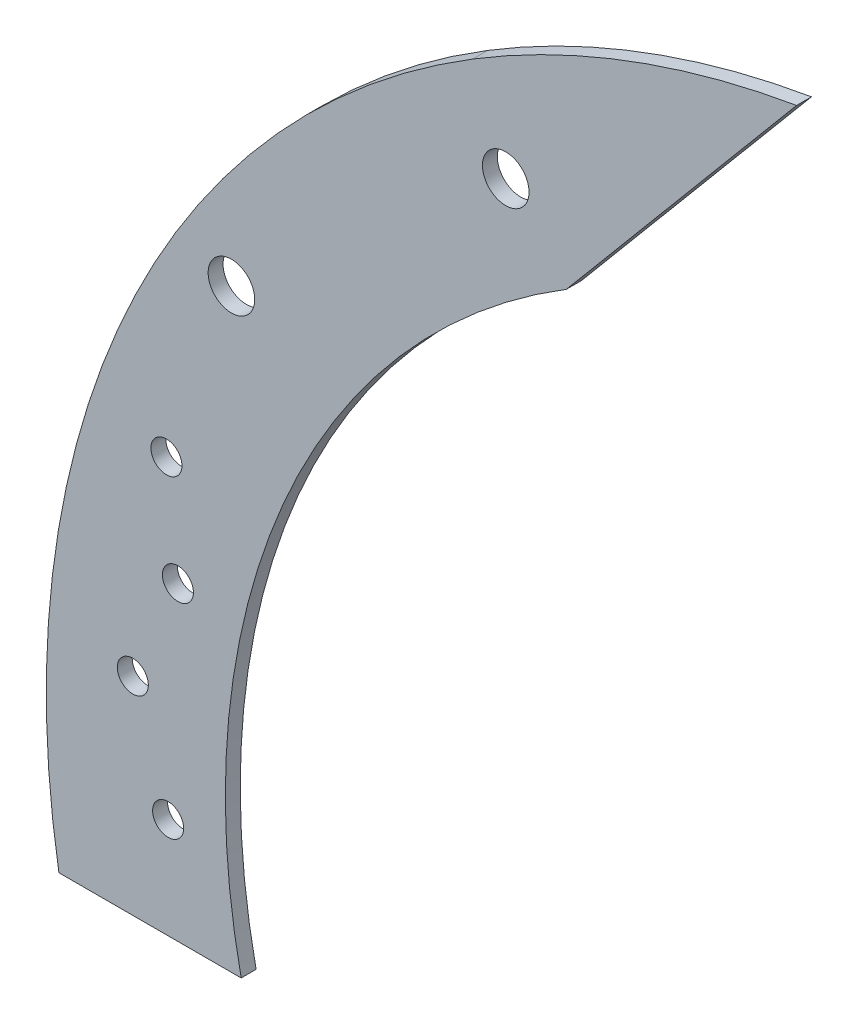
from build123d import *

# Parameters (mm, degrees)
BOSS_EXTRUDE1_DEPTH              = 3.175
SKETCH2_R                        = 3.302
CUT_EXTRUDE1_DEPTH               = 3.175
SKETCH3_R                        = 3.302
CUT_EXTRUDE2_DEPTH               = 3.175
F_25_64_0_39063_DIAMETER_HOLE1_D = 9.922002


with BuildPart() as part:
    # Sketch1 → Boss-Extrude1 (new body)
    with BuildSketch(Plane.XY):
        with BuildLine():
            Line((-150.65739054, -36.5125), (-189.445196846, -36.5125))
            ThreePointArc((-189.445196846, -36.5125), (-175.12424315, 73.983329), (-101.363819659, 157.492716901))
            ThreePointArc((-101.363819659, 157.492716901), (-68.153294369, 173.730017516), (-32.46878203, 183.38426531))
            Line((-32.46878203, 183.38426531), (-81.449197888, 125.011678745))
            ThreePointArc((-81.449197888, 125.011678745), (-141.744884659, 55.257653644), (-150.65739054, -36.5125))
        make_face()
    extrude(amount=BOSS_EXTRUDE1_DEPTH)

    # Sketch2 → Cut-Extrude1 (cut)
    with BuildSketch(Plane.XY.offset(3.175)):
        with Locations((-166.205357894, -15.073647178)):
            Circle(SKETCH2_R)
        with Locations((-164.125827505, 29.433503815)):
            Circle(SKETCH2_R)
    extrude(amount=-CUT_EXTRUDE1_DEPTH, mode=Mode.SUBTRACT)

    # Sketch3 → Cut-Extrude2 (cut)
    with BuildSketch(Plane.XY.offset(3.175)):
        with Locations((-173.718655592, 7.579557452)):
            Circle(SKETCH3_R)
        with Locations((-166.564839951, 51.569288407)):
            Circle(SKETCH3_R)
    extrude(amount=-CUT_EXTRUDE2_DEPTH, mode=Mode.SUBTRACT)

    # 25_64 _0.39063_ Diameter Hole1 (through all)
    with Locations(Plane.XY.offset(3.175)):
        with Locations((-94.36092612, 138.93426531), (-152.733512685, 89.953849452)):
            Hole(F_25_64_0_39063_DIAMETER_HOLE1_D / 2)


solid = part.part
